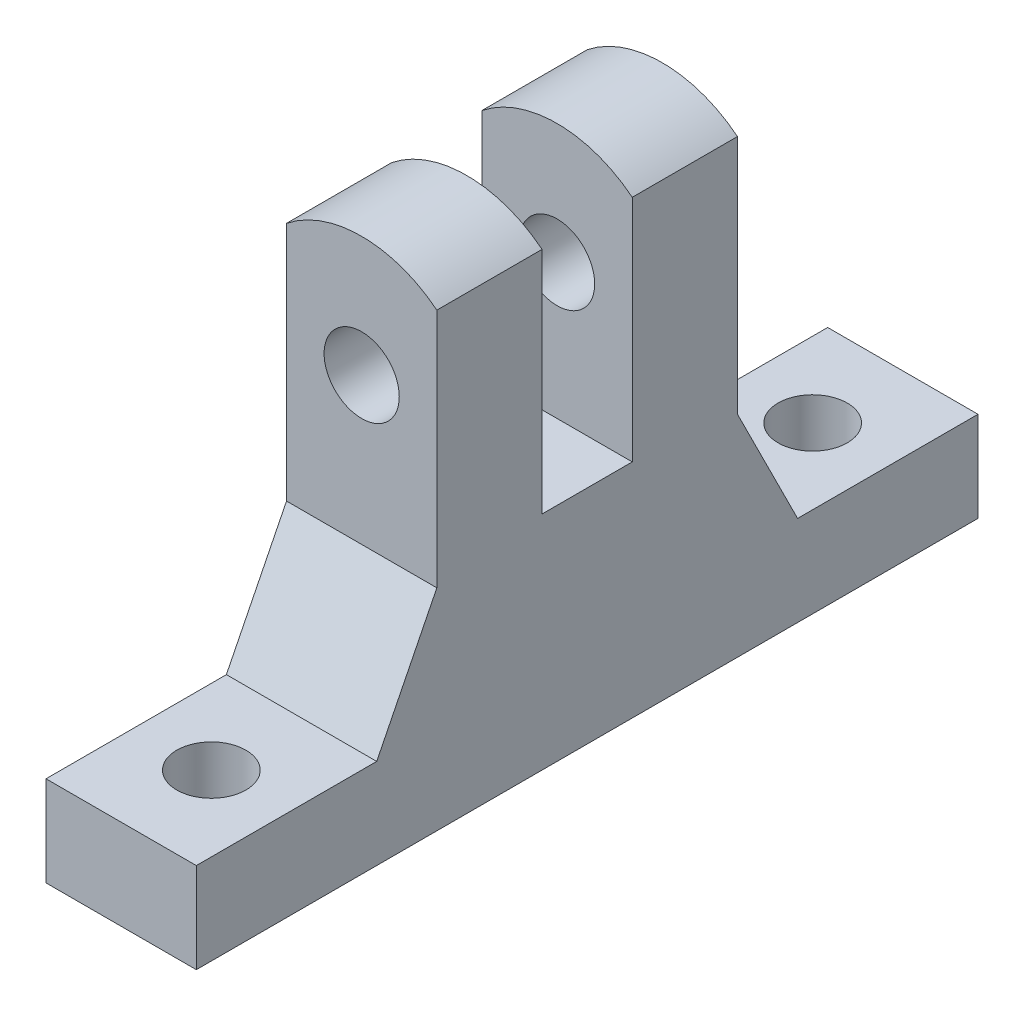
from build123d import *

# Parameters (mm, degrees)
SKETCH1_R           = 1.25
BOSS_EXTRUDE1_DEPTH = 10
SKETCH2_W           = 3
SKETCH2_H           = 8.5
CUT_EXTRUDE1_DEPTH  = 6
SKETCH3_W           = 5
SKETCH3_H           = 26
SKETCH3_R           = 1.15
BOSS_EXTRUDE2_DEPTH = 3
CHAMFER1_SIZE       = 2
CHAMFER1_SIZE2      = 4
CHAMFER2_SIZE       = 4
CHAMFER2_SIZE2      = 2


with BuildPart() as part:
    # Sketch1 → Boss-Extrude1 (new body)
    with BuildSketch(Plane.XY):
        with BuildLine():
            Line((2.5, 15), (2.5, 0))
            Line((2.5, 0), (-2.5, 0))
            Line((-2.5, 0), (-2.5, 15))
            ThreePointArc((-2.5, 15), (0, 15.877501001), (2.5, 15))
        make_face()
        with Locations((0, 11.877501001)):
            Circle(SKETCH1_R, mode=Mode.SUBTRACT)
    extrude(amount=-BOSS_EXTRUDE1_DEPTH)

    # Sketch2 → Cut-Extrude1 (cut, through all)
    with BuildSketch(Plane.ZY.offset(2.5)):
        with Locations((-5, 11.627501001)):
            Rectangle(SKETCH2_W, SKETCH2_H)
    extrude(amount=-CUT_EXTRUDE1_DEPTH, mode=Mode.SUBTRACT)

    # Sketch3 → Boss-Extrude2 (add)
    with BuildSketch(Plane.XZ):
        with Locations((0, -5)):
            Rectangle(SKETCH3_W, SKETCH3_H)
        with Locations((0, 5)):
            Circle(SKETCH3_R, mode=Mode.SUBTRACT)
        with Locations((0, -15)):
            Circle(SKETCH3_R, mode=Mode.SUBTRACT)
    extrude(amount=-BOSS_EXTRUDE2_DEPTH)

    # Chamfer1
    chamfer1_edges = [part.edges().sort_by_distance(p)[0] for p in [
        (0, 3, -10),
    ]]
    chamfer1_side = [part.faces().sort_by_distance(p)[0] for p in [
        (-2.405660189, 3, -14),
    ]]
    chamfer(chamfer1_edges, length=CHAMFER1_SIZE, length2=CHAMFER1_SIZE2, reference=chamfer1_side[0])

    # Chamfer2
    chamfer2_edges = [part.edges().sort_by_distance(p)[0] for p in [
        (0, 3, 0),
    ]]
    chamfer2_side = [part.faces().sort_by_distance(p)[0] for p in [
        (0, 9.084568634, 0),
    ]]
    chamfer(chamfer2_edges, length=CHAMFER2_SIZE, length2=CHAMFER2_SIZE2, reference=chamfer2_side[0])


solid = part.part
